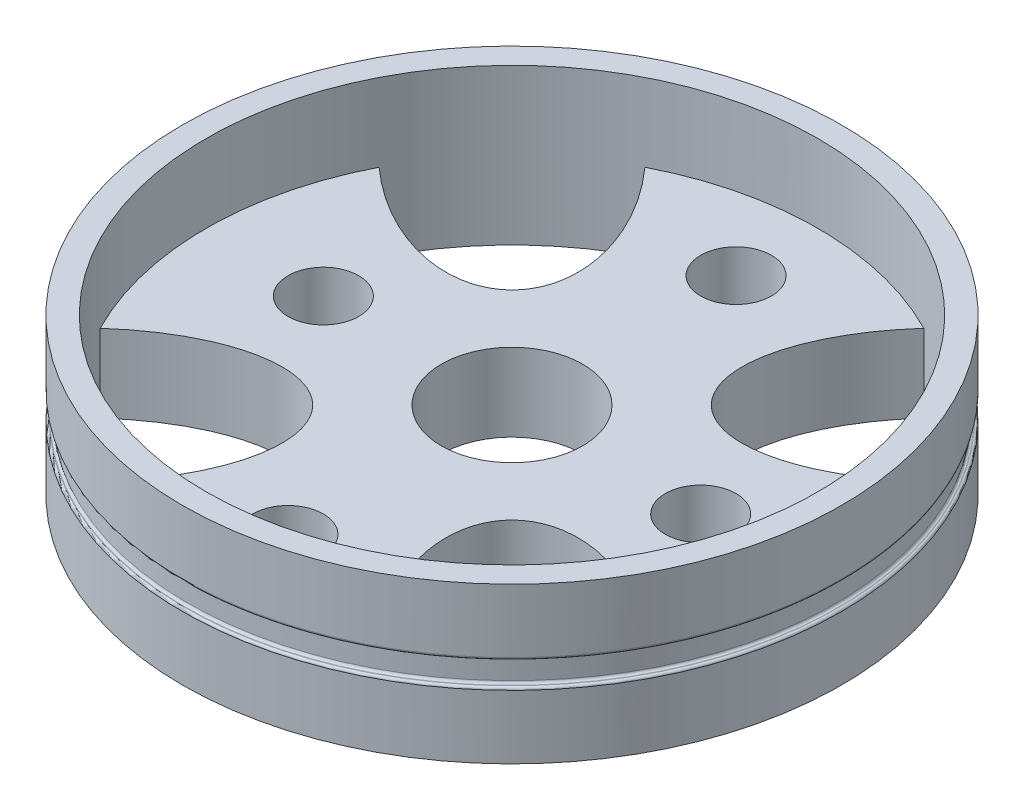
from build123d import *

# Parameters (mm, degrees)
SKETCH1_R               = 13.975
BOSS_EXTRUDE1_DEPTH     = 6.6
SKETCH2_R               = 12.975
CUT_EXTRUDE1_DEPTH      = 3.3
SKETCH4_R               = 13.975
SKETCH4_R_2             = 13.75
CUT_EXTRUDE2_DEPTH      = 0.5
CUT_EXTRUDE2_DEPTH_BACK = 0.5
FILLET1_R               = 0.1
SKETCH5_R               = 3
SKETCH5_R_2             = 1.5
CUT_EXTRUDE4_DEPTH      = 3.3


with BuildPart() as part:
    # Sketch1 → Boss-Extrude1 (new body)
    with BuildSketch(Plane(origin=(0, 0, 0), x_dir=(1, 0, 0), z_dir=(0, 1, 0))):
        Circle(SKETCH1_R)
    extrude(amount=BOSS_EXTRUDE1_DEPTH)

    # Sketch2 → Cut-Extrude1 (cut)
    with BuildSketch(Plane(origin=(0, 6.6, 0), x_dir=(1, 0, 0), z_dir=(0, 1, 0))):
        Circle(SKETCH2_R)
    extrude(amount=-CUT_EXTRUDE1_DEPTH, mode=Mode.SUBTRACT)

    # Sketch4 → Cut-Extrude2 (cut, two sides)
    with BuildSketch(Plane(origin=(0, 3.3, 13.975), x_dir=(1, 0, 0), z_dir=(0, 1, 0))) as cut_extrude2_sk:
        with Locations((0, 13.975)):
            Circle(SKETCH4_R)
        with Locations((0, 13.975)):
            Circle(SKETCH4_R_2, mode=Mode.SUBTRACT)
    extrude(amount=CUT_EXTRUDE2_DEPTH, mode=Mode.SUBTRACT)
    extrude(cut_extrude2_sk.sketch, amount=-CUT_EXTRUDE2_DEPTH_BACK, mode=Mode.SUBTRACT)

    # Fillet1
    fillet1_edges = [part.edges().sort_by_distance(p)[0] for p in [
        (-13.975, 3.8, 0),
        (-13.975, 2.8, 0),
        (-13.75, 3.8, 0),
        (-13.75, 2.8, 0),
    ]]
    fillet(fillet1_edges, radius=FILLET1_R)

    # Sketch5 → Cut-Extrude4 (cut)
    with BuildSketch(Plane(origin=(0, 3.3, 0), x_dir=(1, 0, 0), z_dir=(0, 1, 0))):
        Circle(SKETCH5_R)
        with Locations((8, 0)):
            Circle(SKETCH5_R_2)
        with Locations((0, 9.5)):
            Circle(SKETCH5_R_2)
        with Locations((0, -9.5)):
            Circle(SKETCH5_R_2)
        with Locations((-8, 0)):
            Circle(SKETCH5_R_2)
        with BuildLine():
            ThreePointArc((11.548586923, -5.914453913), (9.174710486, -9.174710486), (5.914453913, -11.548586923))
            add(Edge.make_bspline(
                [(11.548586923, -5.914453913), (6.810523801, -1.639402234), (4.224963018, -4.224963018), (1.639402234, -6.810523801), (5.914453913, -11.548586923)],
                knots=[1.660454314, 1.660454314, 1.660454314, 3.141592654, 3.141592654, 4.622730994, 4.622730994, 4.622730994], degree=2, weights=[1, 0.738084655, 1, 0.738084655, 1]))
        make_face()
        with BuildLine():
            ThreePointArc((-5.914453913, -11.548586923), (-9.174710486, -9.174710486), (-11.548586923, -5.914453913))
            add(Edge.make_bspline(
                [(-5.914453913, -11.548586923), (-1.639402234, -6.810523801), (-4.224963018, -4.224963018), (-6.810523801, -1.639402234), (-11.548586923, -5.914453913)],
                knots=[1.660454314, 1.660454314, 1.660454314, 3.141592654, 3.141592654, 4.622730994, 4.622730994, 4.622730994], degree=2, weights=[1, 0.738084655, 1, 0.738084655, 1]))
        make_face()
        with BuildLine():
            ThreePointArc((-11.548586923, 5.914453913), (-9.174710486, 9.174710486), (-5.914453913, 11.548586923))
            add(Edge.make_bspline(
                [(-11.548586923, 5.914453913), (-6.810523801, 1.639402234), (-4.224963018, 4.224963018), (-1.639402234, 6.810523801), (-5.914453913, 11.548586923)],
                knots=[1.660454314, 1.660454314, 1.660454314, 3.141592654, 3.141592654, 4.622730994, 4.622730994, 4.622730994], degree=2, weights=[1, 0.738084655, 1, 0.738084655, 1]))
        make_face()
        with BuildLine():
            ThreePointArc((5.914453913, 11.548586923), (9.174710486, 9.174710486), (11.548586923, 5.914453913))
            add(Edge.make_bspline(
                [(5.914453913, 11.548586923), (1.639402234, 6.810523801), (4.224963018, 4.224963018), (6.810523801, 1.639402234), (11.548586923, 5.914453913)],
                knots=[4.802046967, 4.802046967, 4.802046967, 6.283185307, 6.283185307, 7.764323647, 7.764323647, 7.764323647], degree=2, weights=[1, 0.738084655, 1, 0.738084655, 1]))
        make_face()
    extrude(amount=-CUT_EXTRUDE4_DEPTH, mode=Mode.SUBTRACT)


solid = part.part
